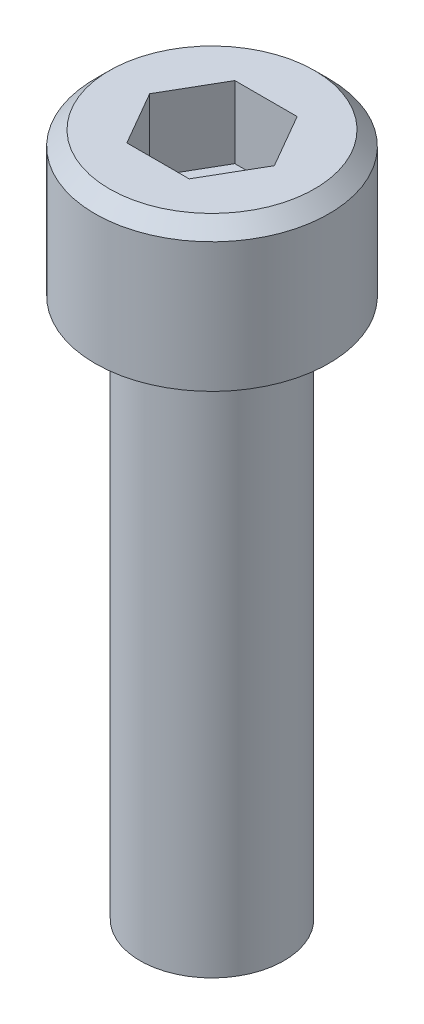
from build123d import *

# Parameters (mm, degrees)
CUT_EXTRUDE1_DEPTH = 4
CHAMFER1_SIZE      = 0.8


with BuildPart() as part:
    # Sketch1 → Revolve1 (revolve)
    with BuildSketch(Plane.XY):
        Polygon((0, 8), (6.5, 8), (6.5, 0), (4, 0), (4, -30), (0, -30), align=None)
    revolve(axis=Axis((0, 0, 0), (0, 1, 0)))

    # Sketch2 → Cut-Extrude1 (cut)
    with BuildSketch(Plane(origin=(0, 8, 0), x_dir=(1, 0, 0), z_dir=(0, 1, 0))):
        Polygon((3.464101615, 0), (1.732050808, 3), (-1.732050808, 3), (-3.464101615, 0), (-1.732050808, -3), (1.732050808, -3), align=None)
    extrude(amount=-CUT_EXTRUDE1_DEPTH, mode=Mode.SUBTRACT)

    # Chamfer1
    chamfer1_edges = [part.edges().sort_by_distance(p)[0] for p in [
        (-6.5, 8, 0),
    ]]
    chamfer(chamfer1_edges, length=CHAMFER1_SIZE)


solid = part.part
